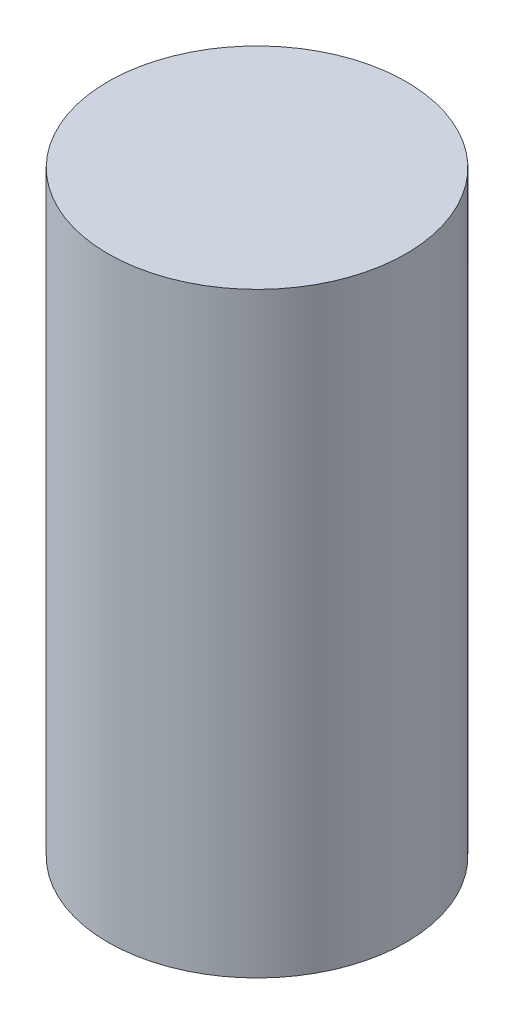
from build123d import *

# Parameters (mm, degrees)
SKETCH1_R           = 9.525
BOSS_EXTRUDE1_DEPTH = 38.1


with BuildPart() as part:
    # Sketch1 → Boss-Extrude1 (new body)
    with BuildSketch(Plane(origin=(0, 0, 0), x_dir=(1, 0, 0), z_dir=(0, 1, 0))):
        Circle(SKETCH1_R)
    extrude(amount=BOSS_EXTRUDE1_DEPTH)


solid = part.part
